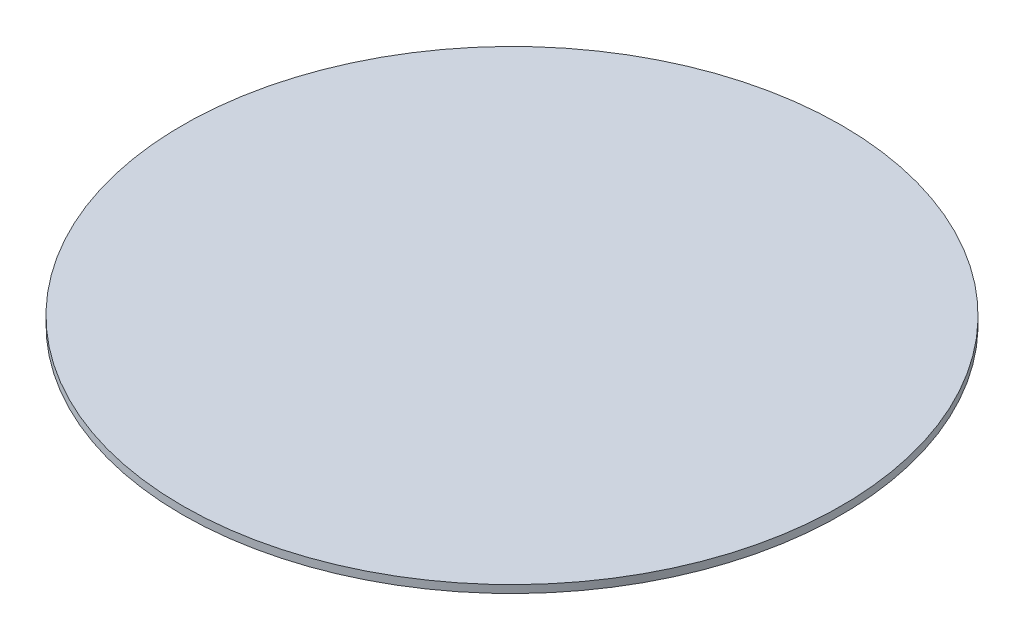
from build123d import *

# Parameters (mm, degrees)
SKIZZE1_R                       = 850
AUFSATZ_LINEAR_AUSTRAGEN1_DEPTH = 20


with BuildPart() as part:
    # Skizze1 → Aufsatz-Linear austragen1 (new body)
    with BuildSketch(Plane(origin=(0, 0, 0), x_dir=(1, 0, 0), z_dir=(0, 1, 0))):
        with Locations(Location((0, 0, 0), (0, 0, 270))):  # turned: the seam where the file's is
            Circle(SKIZZE1_R)
    extrude(amount=AUFSATZ_LINEAR_AUSTRAGEN1_DEPTH)


solid = part.part
